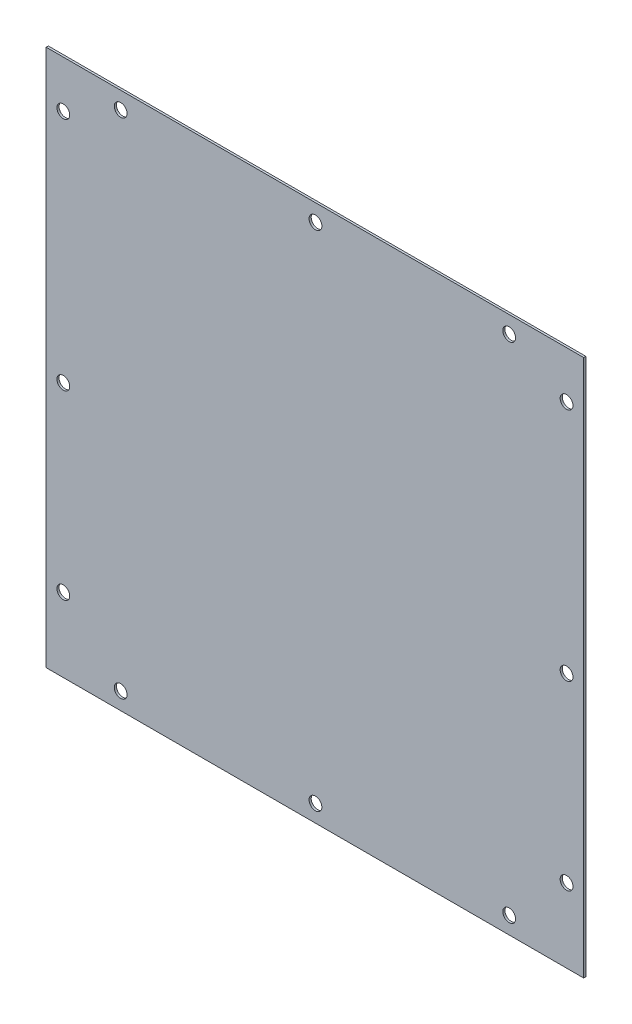
from build123d import *

# Parameters (mm, degrees)
CROQUIS1_W              = 400
CROQUIS1_H              = 400
CROQUIS1_R              = 4.7625
SALIENTE_EXTRUIR1_DEPTH = 1.5875


with BuildPart() as part:
    # Croquis1 → Saliente-Extruir1 (new body)
    with BuildSketch(Plane.XY):
        with Locations((200, 200)):
            Rectangle(CROQUIS1_W, CROQUIS1_H)
        with Locations((55.4, 387.3)):
            Circle(CROQUIS1_R, mode=Mode.SUBTRACT)
        with Locations((200.4, 387.3)):
            Circle(CROQUIS1_R, mode=Mode.SUBTRACT)
        with Locations((344.6, 387.3)):
            Circle(CROQUIS1_R, mode=Mode.SUBTRACT)
        with Locations((12.7, 365)):
            Circle(CROQUIS1_R, mode=Mode.SUBTRACT)
        with Locations((12.7, 190)):
            Circle(CROQUIS1_R, mode=Mode.SUBTRACT)
        with Locations((12.7, 55)):
            Circle(CROQUIS1_R, mode=Mode.SUBTRACT)
        with Locations((387.3, 365)):
            Circle(CROQUIS1_R, mode=Mode.SUBTRACT)
        with Locations((387.3, 190)):
            Circle(CROQUIS1_R, mode=Mode.SUBTRACT)
        with Locations((387.3, 55)):
            Circle(CROQUIS1_R, mode=Mode.SUBTRACT)
        with Locations((344.6, 12.7)):
            Circle(CROQUIS1_R, mode=Mode.SUBTRACT)
        with Locations((200.4, 12.7)):
            Circle(CROQUIS1_R, mode=Mode.SUBTRACT)
        with Locations((55.4, 12.7)):
            Circle(CROQUIS1_R, mode=Mode.SUBTRACT)
    extrude(amount=SALIENTE_EXTRUIR1_DEPTH)


solid = part.part
